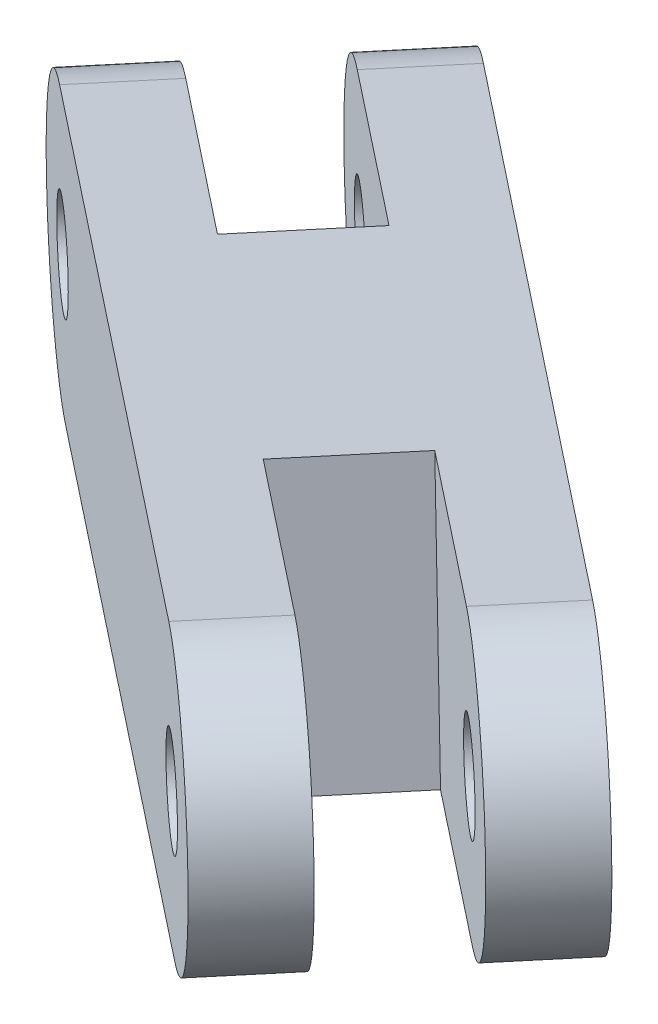
from build123d import *

# Parameters (mm, degrees)
BOSS_EXTRUDE1_DEPTH      = 5.334
BOSS_EXTRUDE1_DEPTH_BACK = 5.334
SKETCH1_R                = 1.651
CUT_EXTRUDE1_DEPTH       = 10.414


with BuildPart() as part:
    # Sketch1 → Boss-Extrude1 (new, two sides: drawn at the far end of the back side and taken through both)
    with BuildSketch(Plane(origin=(10.702221059, 0, -12.754410396), x_dir=(0.7660444431189798, 0, 0.6427876096865374), z_dir=(-0.6427876096865374, 0, 0.7660444431189798)).offset(-BOSS_EXTRUDE1_DEPTH_BACK)):
        with BuildLine():
            Line((-32.691973638, 7.79265549), (-1.277889133, 13.436683202))
            ThreePointArc((-1.277889133, 13.436683202), (4.178001254, 9.642679764), (0.383997817, 4.186789377))
            Line((0.383997817, 4.186789377), (-31.030086688, -1.457238335))
            ThreePointArc((-31.030086688, -1.457238335), (-36.485977075, 2.336765102), (-32.691973638, 7.79265549))
        make_face()
        with Locations((-31.861030163, 3.167708577)):
            Circle(SKETCH1_R, mode=Mode.SUBTRACT)
        with Locations((-0.446945658, 8.811736289)):
            Circle(SKETCH1_R, mode=Mode.SUBTRACT)
    extrude(amount=BOSS_EXTRUDE1_DEPTH + BOSS_EXTRUDE1_DEPTH_BACK)

    # Sketch3 → Cut-Extrude1 (cut)
    with BuildSketch(Plane(origin=(-1.822096994, 13.238927242, -1.528920916), x_dir=(0.990782435050318, 0.13456837613179015, -0.015540866803864855), z_dir=(-0.13546278601801462, 0.9842406708429238, -0.1136667737859623))):
        Polygon((-17.612221816, 34.057028648), (-6.98123986, 24.993744329), (-4.17986107, 28.279684206), (-14.810843026, 37.342968525), align=None)
        Polygon((16.629373849, 10.539082885), (5.998391893, 19.602367204), (3.197013104, 16.316427327), (13.82799506, 7.253143007), align=None)
    extrude(amount=-CUT_EXTRUDE1_DEPTH, mode=Mode.SUBTRACT)


solid = part.part
